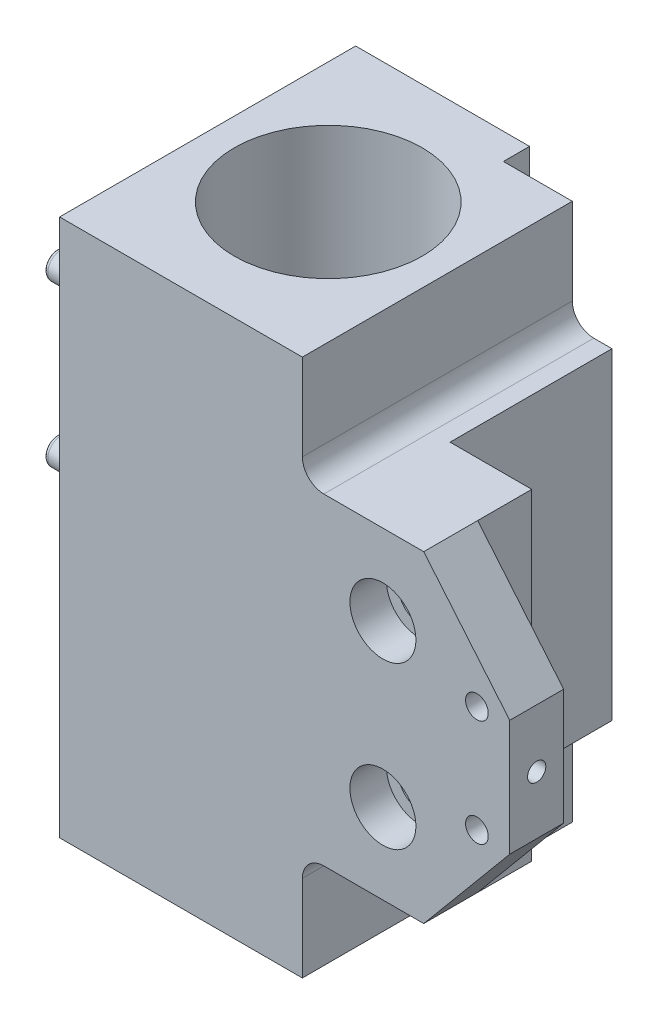
from build123d import *

# Parameters (mm, degrees)
BOSS_EXTRUDE1_DEPTH      = 31.765
BOSS_EXTRUDE1_DEPTH_BACK = 31.765
SKETCH1_R                = 11.1
SKETCH2_W                = 12.73
SKETCH2_H                = 38.12
BOSS_EXTRUDE2_DEPTH      = 9.43
CUT_EXTRUDE1_DEPTH       = 62.165032698
CHAMFER1_SIZE            = 1.6
SKETCH4_R                = 1.41
CUT_EXTRUDE2_DEPTH       = 11
SKETCH5_R                = 2.445
CUT_EXTRUDE3_DEPTH       = 55.875215034
SKETCH6_R                = 3.9
CUT_EXTRUDE4_DEPTH       = 4.32
SKETCH7_R                = 1.34
CUT_EXTRUDE5_DEPTH       = 58.75892074
SKETCH8_R                = 2
CUT_EXTRUDE6_DEPTH       = 10.5
SKETCH9_R                = 1.57
BOSS_EXTRUDE3_DEPTH      = 8.3
FILLET1_R                = 0.5
SKETCH10_R               = 1.075
CUT_EXTRUDE7_DEPTH       = 6.35


with BuildPart() as part:
    # Sketch1 → Boss-Extrude1 (new, two sides: drawn at the far end of the back side and taken through both)
    with BuildSketch(Plane(origin=(0, 0, 0), x_dir=(1, 0, 0), z_dir=(0, 1, 0)).offset(-BOSS_EXTRUDE1_DEPTH_BACK)):
        Polygon((-14.34, 17.58), (-14.34, -17.4), (38.84, -17.4), (38.84, -11.03), (28.68, -11.03), (28.68, -4.64), (19.03, -4.64), (19.03, 14.49), (14.34, 14.49), (6.2, 14.49), (6.2, 17.58), align=None)
        Circle(SKETCH1_R, mode=Mode.SUBTRACT)
    extrude(amount=BOSS_EXTRUDE1_DEPTH + BOSS_EXTRUDE1_DEPTH_BACK)

    # Sketch2 → Boss-Extrude2 (add)
    with BuildSketch(Plane.ZY.offset(14.34)):
        Rectangle(SKETCH2_W, SKETCH2_H)
    extrude(amount=BOSS_EXTRUDE2_DEPTH)

    # Sketch3 → Cut-Extrude1 (cut, through all)
    with BuildSketch(Plane(origin=(0, 0, -17.58), x_dir=(-1, 0, 0), z_dir=(0, 0, -1))):
        with BuildLine():
            Line((-38.84, 6.85), (-28.68, 19.025))
            Line((-28.68, 19.025), (-16.88, 19.025))
            ThreePointArc((-16.88, 19.025), (-15.083948776, 19.768948776), (-14.34, 21.565))
            Line((-14.34, 21.565), (-14.34, 31.765))
            Line((-14.34, 31.765), (-38.84, 31.765))
            Line((-38.84, 31.765), (-38.84, 6.85))
        make_face()
        with BuildLine():
            Line((-28.68, -19.025), (-16.88, -19.025))
            ThreePointArc((-16.88, -19.025), (-15.083948776, -19.768948776), (-14.34, -21.565))
            Line((-14.34, -21.565), (-14.34, -31.765))
            Line((-14.34, -31.765), (-38.84, -31.765))
            Line((-38.84, -31.765), (-38.84, -6.85))
            Line((-38.84, -6.85), (-28.68, -19.025))
        make_face()
    extrude(amount=-CUT_EXTRUDE1_DEPTH, mode=Mode.SUBTRACT)

    # Chamfer1
    chamfer1_edges = [part.edges().sort_by_distance(p)[0] for p in [
        (-23.77, -19.06, 0),
    ]]
    chamfer(chamfer1_edges, length=CHAMFER1_SIZE)

    # Sketch4 → Cut-Extrude2 (cut)
    with BuildSketch(Plane(origin=(0, 0, -14.49), x_dir=(-1, 0, 0), z_dir=(0, 0, -1))):
        with Locations((-12.48, 0)):
            Circle(SKETCH4_R)
    extrude(amount=-CUT_EXTRUDE2_DEPTH, mode=Mode.SUBTRACT)

    # Sketch5 → Cut-Extrude3 (cut, through all)
    with BuildSketch(Plane(origin=(0, 0, 4.64), x_dir=(-1, 0, 0), z_dir=(0, 0, -1))):
        with Locations((-23.855, -9.53)):
            Circle(SKETCH5_R)
        with Locations((-23.855, 9.53)):
            Circle(SKETCH5_R)
    extrude(amount=-CUT_EXTRUDE3_DEPTH, mode=Mode.SUBTRACT)

    # Sketch6 → Cut-Extrude4 (cut)
    with BuildSketch(Plane.XY.offset(17.4)):
        with Locations((23.855, -9.53)):
            Circle(SKETCH6_R)
        with Locations((23.855, 9.53)):
            Circle(SKETCH6_R)
    extrude(amount=-CUT_EXTRUDE4_DEPTH, mode=Mode.SUBTRACT)

    # Sketch7 → Cut-Extrude5 (cut, through all)
    with BuildSketch(Plane(origin=(0, 0, 11.03), x_dir=(-1, 0, 0), z_dir=(0, 0, -1))):
        with Locations((-34.96, 6.31)):
            Circle(SKETCH7_R)
        with Locations((-34.96, -6.31)):
            Circle(SKETCH7_R)
    extrude(amount=-CUT_EXTRUDE5_DEPTH, mode=Mode.SUBTRACT)

    # Sketch8 → Cut-Extrude6 (cut)
    with BuildSketch(Plane.ZY.offset(23.77)):
        Circle(SKETCH8_R)
    extrude(amount=-CUT_EXTRUDE6_DEPTH, mode=Mode.SUBTRACT)

    # Sketch9 → Boss-Extrude3 (add)
    with BuildSketch(Plane.ZY.offset(23.77)):
        with Locations((0, -9.505)):
            Circle(SKETCH9_R)
        with Locations((0, 9.505)):
            Circle(SKETCH9_R)
    extrude(amount=BOSS_EXTRUDE3_DEPTH)

    # Fillet1
    fillet1_edges = [part.edges().sort_by_distance(p)[0] for p in [
        (-32.07, 9.505, -1.57),
        (-32.07, -9.505, -1.57),
    ]]
    fillet(fillet1_edges, radius=FILLET1_R)

    # Sketch10 → Cut-Extrude7 (cut)
    with BuildSketch(Plane(origin=(38.84, 0, 0), x_dir=(0, 0, -1), z_dir=(1, 0, 0))):
        with Locations((-14.215, 0)):
            Circle(SKETCH10_R)
    extrude(amount=-CUT_EXTRUDE7_DEPTH, mode=Mode.SUBTRACT)


solid = part.part
